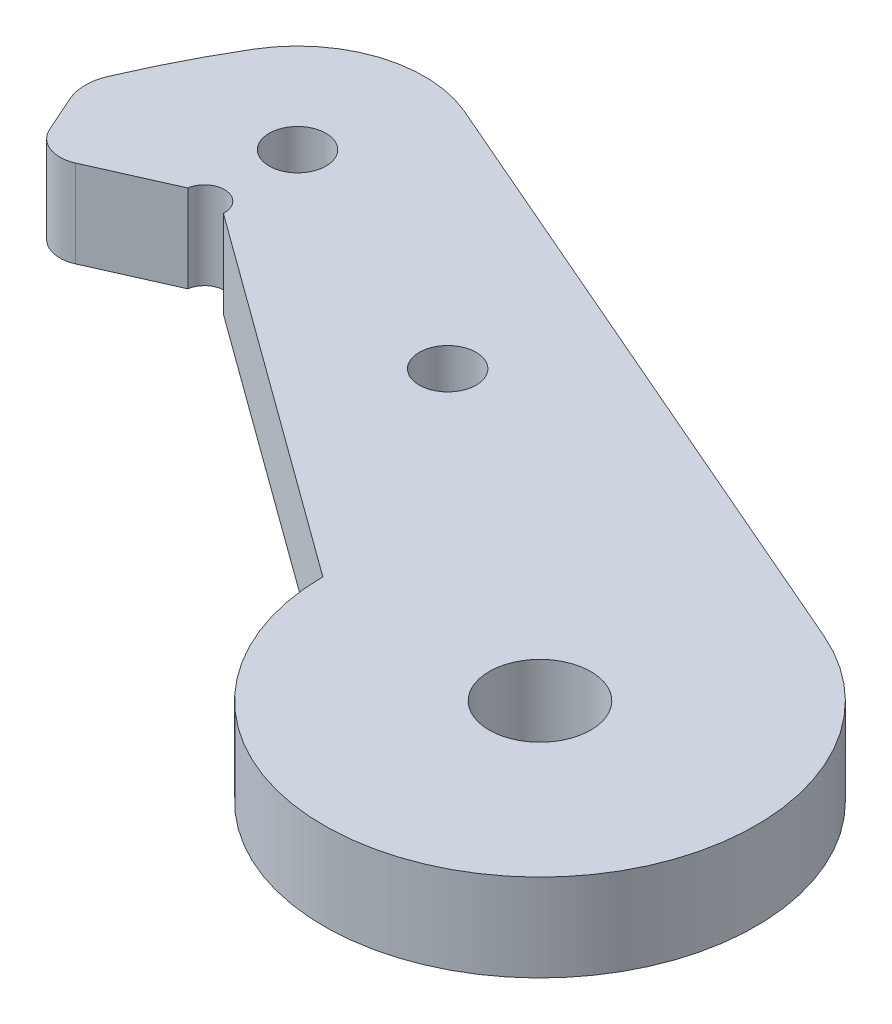
from build123d import *

# Parameters (mm, degrees)
SKETCH1_R           = 1.778
SKETCH1_R_2         = 3.175
BOSS_EXTRUDE1_DEPTH = 5.461


with BuildPart() as part:
    # Sketch1 → Boss-Extrude1 (new body)
    with BuildSketch(Plane(origin=(0, 0, 0), x_dir=(1, 0, 0), z_dir=(0, 1, 0))):
        with BuildLine():
            Line((-38.770225031, 16.757963615), (-43.625448569, 14.598747375))
            ThreePointArc((-43.625448569, 14.598747375), (-45.155674622, 14.559326862), (-46.265582353, 15.613485569))
            Line((-46.265582353, 15.613485569), (-47.282683039, 17.900542834))
            ThreePointArc((-47.282683039, 17.900542834), (-47.541465806, 19.100109045), (-47.298283286, 20.302934833))
            ThreePointArc((-47.298283286, 20.302934833), (-45.865213893, 23.360627542), (-44.234733225, 26.317772344))
            ThreePointArc((-44.234733225, 26.317772344), (-39.855484626, 29.811728531), (-34.259632886, 29.543416329))
            Line((-34.259632886, 29.543416329), (5.363638877, 12.388760148))
            ThreePointArc((5.363638877, 12.388760148), (7.44200849, -11.263503435), (-13.499793526, -0.074664302))
            Line((-13.499793526, -0.074664302), (-36.286855081, 16.495885282))
            ThreePointArc((-36.286855081, 16.495885282), (-37.403602541, 17.810792136), (-38.770225031, 16.757963615))
        make_face()
        with Locations((-20.862458922, 15.093717491)):
            Circle(SKETCH1_R, mode=Mode.SUBTRACT)
        Circle(SKETCH1_R_2, mode=Mode.SUBTRACT)
        with Locations((-37.413253893, 22.259284205)):
            Circle(SKETCH1_R, mode=Mode.SUBTRACT)
    extrude(amount=BOSS_EXTRUDE1_DEPTH)


solid = part.part
